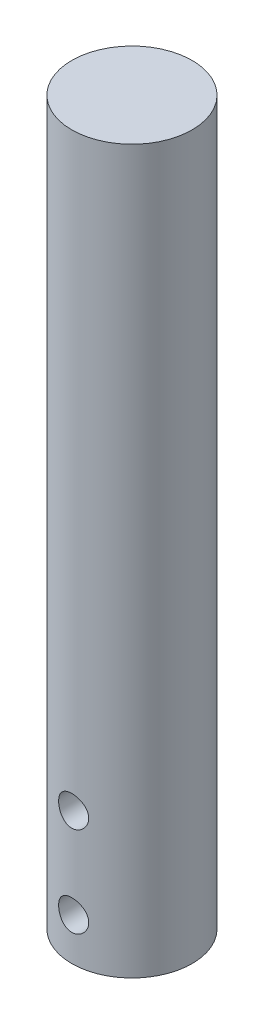
from build123d import *

# Parameters (mm, degrees)
SKETCH1_R           = 12.7
BOSS_EXTRUDE1_DEPTH = 152.4
SKETCH2_R           = 3.175
CUT_EXTRUDE1_DEPTH  = 26.4


with BuildPart() as part:
    # Sketch1 → Boss-Extrude1 (new body)
    with BuildSketch(Plane(origin=(0, 0, 0), x_dir=(1, 0, 0), z_dir=(0, 1, 0))):
        Circle(SKETCH1_R)
    extrude(amount=BOSS_EXTRUDE1_DEPTH)

    # Sketch2 → Cut-Extrude1 (cut, through all)
    with BuildSketch(Plane.XY.offset(12.7)):
        with Locations((0, 27.94)):
            Circle(SKETCH2_R)
        with Locations((0, 8.89)):
            Circle(SKETCH2_R)
    extrude(amount=-CUT_EXTRUDE1_DEPTH, mode=Mode.SUBTRACT)


solid = part.part
